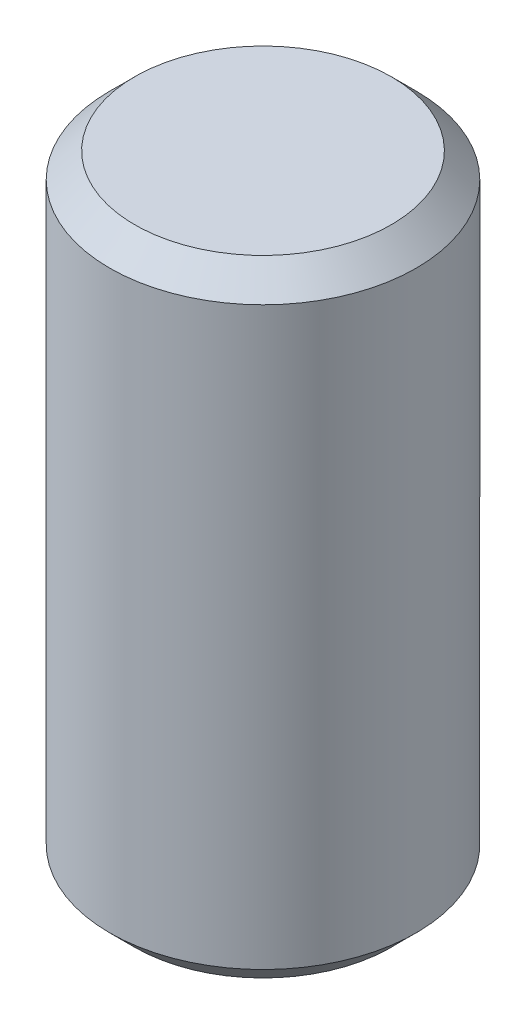
from build123d import *

# Parameters (mm, degrees)
SKETCH1_W     = 3.1115
SKETCH1_H     = 12.7
CHAMFER1_SIZE = 0.508


with BuildPart() as part:
    # Sketch1 → Revolve1 (revolve)
    with BuildSketch(Plane.XY):
        with Locations((1.55575, 0)):
            Rectangle(SKETCH1_W, SKETCH1_H)
    revolve(axis=Axis((0, 6.080207887, 0), (0, -1, 0)))

    # Chamfer1
    chamfer1_edges = [part.edges().sort_by_distance(p)[0] for p in [
        (-3.1115, 6.35, 0),
        (-3.1115, -6.35, 0),
    ]]
    chamfer(chamfer1_edges, length=CHAMFER1_SIZE)


solid = part.part
